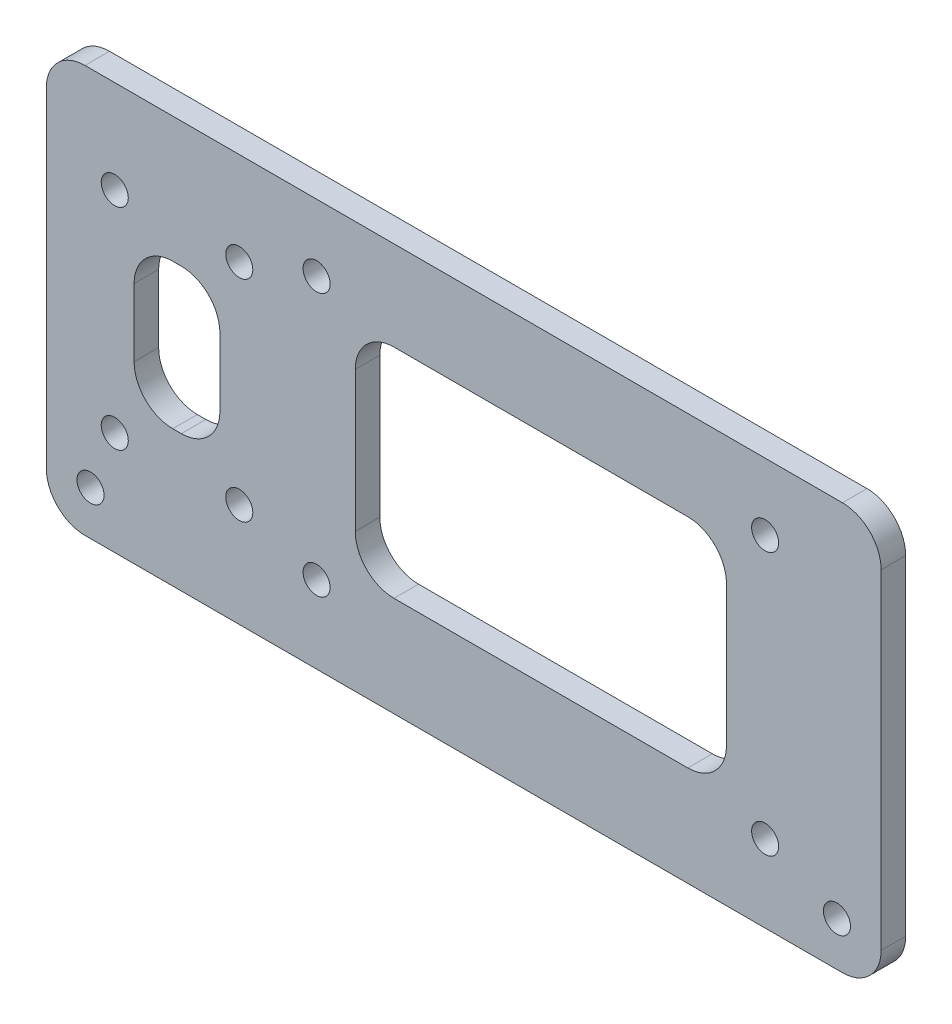
from build123d import *

# Parameters (mm, degrees)
SKETCH1_W           = 107.95
SKETCH1_H           = 87.63
BOSS_EXTRUDE1_DEPTH = 3.175
SKETCH2_R           = 1.75
CUT_EXTRUDE1_DEPTH  = 4.175
SKETCH3_R           = 1.75
SKETCH3_W           = 48
SKETCH3_H           = 28.137931034
SKETCH3_W_2         = 11.1
SKETCH3_H_2         = 18.752795032
CUT_EXTRUDE2_DEPTH  = 4.175
SKETCH4_W           = 107.95
SKETCH4_H           = 35
CUT_EXTRUDE3_DEPTH  = 4.175
FILLET1_R           = 5


with BuildPart() as part:
    # Sketch1 → Boss-Extrude1 (new body)
    with BuildSketch(Plane.XY):
        Rectangle(SKETCH1_W, SKETCH1_H)
    extrude(amount=BOSS_EXTRUDE1_DEPTH)

    # Sketch2 → Cut-Extrude1 (cut, through all)
    with BuildSketch(Plane.XY.offset(3.175)):
        with Locations((-48.26, 38.1)):
            Circle(SKETCH2_R)
        with Locations((48.26, 38.1)):
            Circle(SKETCH2_R)
        with Locations((48.26, -38.1)):
            Circle(SKETCH2_R)
        with Locations((-48.26, -38.1)):
            Circle(SKETCH2_R)
    extrude(amount=-CUT_EXTRUDE1_DEPTH, mode=Mode.SUBTRACT)

    # Sketch3 → Cut-Extrude2 (cut, through all)
    with BuildSketch(Plane.XY.offset(3.175)):
        with Locations((-29.025, -3.215)):
            Circle(SKETCH3_R)
        with Locations((-29.025, -30.415)):
            Circle(SKETCH3_R)
        with Locations((-45.125, -30.415)):
            Circle(SKETCH3_R)
        with Locations((-45.125, -3.215)):
            Circle(SKETCH3_R)
        with Locations((-19.025, -33.815)):
            Circle(SKETCH3_R)
        with Locations((38.975, -33.815)):
            Circle(SKETCH3_R)
        with Locations((38.975, 0.185)):
            Circle(SKETCH3_R)
        with Locations((-19.025, 0.185)):
            Circle(SKETCH3_R)
        with Locations((9.975, -16.815)):
            Rectangle(SKETCH3_W, SKETCH3_H)
        with Locations((-37.075, -16.815)):
            Rectangle(SKETCH3_W_2, SKETCH3_H_2)
    extrude(amount=-CUT_EXTRUDE2_DEPTH, mode=Mode.SUBTRACT)

    # Sketch4 → Cut-Extrude3 (cut, through all)
    with BuildSketch(Plane.XY.offset(3.175)):
        with Locations((0, 26.315)):
            Rectangle(SKETCH4_W, SKETCH4_H)
    extrude(amount=-CUT_EXTRUDE3_DEPTH, mode=Mode.SUBTRACT)

    # Fillet1
    fillet1_edges = [part.edges().sort_by_distance(p)[0] for p in [
        (-53.975, 8.815, 1.5875),
        (53.975, 8.815, 1.5875),
        (33.975, -2.746034483, 1.5875),
        (33.975, -30.883965517, 1.5875),
        (-14.025, -30.883965517, 1.5875),
        (-14.025, -2.746034483, 1.5875),
        (-31.525, -7.438602484, 1.5875),
        (-31.525, -26.191397516, 1.5875),
        (-42.625, -26.191397516, 1.5875),
        (-42.625, -7.438602484, 1.5875),
        (53.975, -43.815, 1.5875),
        (-53.975, -43.815, 1.5875),
    ]]
    fillet(fillet1_edges, radius=FILLET1_R)


solid = part.part
